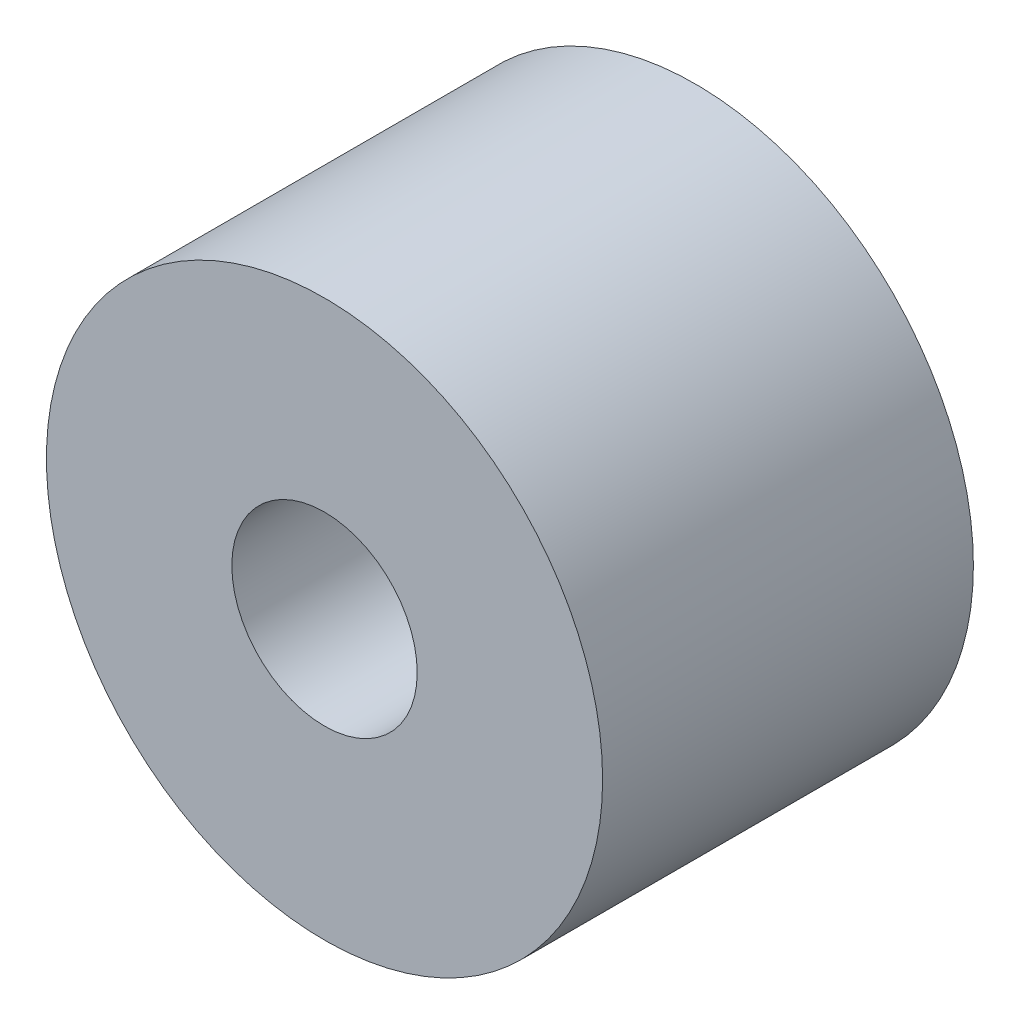
from build123d import *

# Parameters (mm, degrees)
SKETCH1_R           = 15
BOSS_EXTRUDE1_DEPTH = 20
SKETCH2_R           = 5
CUT_EXTRUDE1_DEPTH  = 10


with BuildPart() as part:
    # Sketch1 → Boss-Extrude1 (new body)
    with BuildSketch(Plane.XY):
        Circle(SKETCH1_R)
    extrude(amount=BOSS_EXTRUDE1_DEPTH)

    # Sketch2 → Cut-Extrude1 (cut)
    with BuildSketch(Plane.XY.offset(20)):
        Circle(SKETCH2_R)
    extrude(amount=-CUT_EXTRUDE1_DEPTH, mode=Mode.SUBTRACT)


solid = part.part
